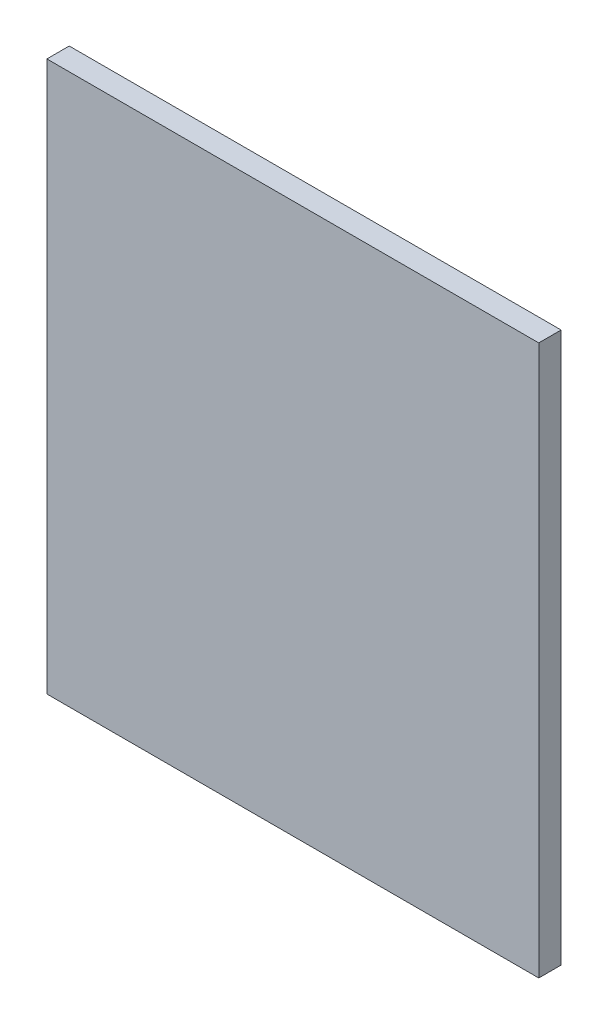
from build123d import *

# Parameters (mm, degrees)
SKETCH1_W           = 139.7
SKETCH1_H           = 156.21
BOSS_EXTRUDE1_DEPTH = 6.35


with BuildPart() as part:
    # Sketch1 → Boss-Extrude1 (new body)
    with BuildSketch(Plane.XY):
        with Locations((69.85, 78.105)):
            Rectangle(SKETCH1_W, SKETCH1_H)
    extrude(amount=BOSS_EXTRUDE1_DEPTH)


solid = part.part
